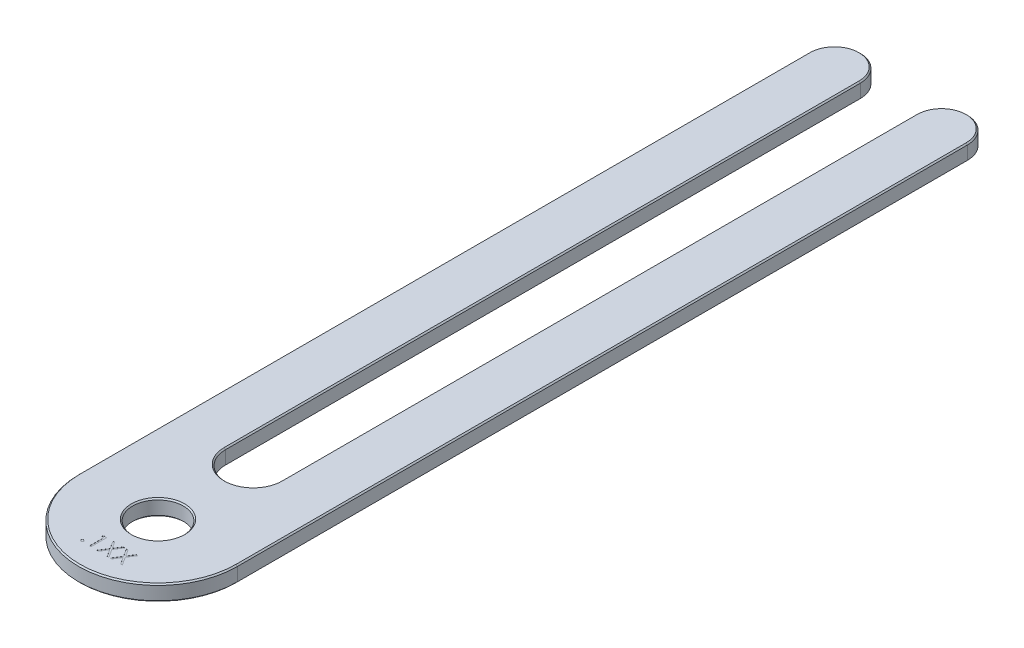
from build123d import *

# Parameters (mm, degrees)
SKETCH1_R          = 5.08
BASE_EXTRUDE_DEPTH = 1.5875
CHAMFER1_SIZE      = 0.254
EXTRUDE1_DEPTH     = 0.0254


with BuildPart() as part:
    # Sketch1 → Base-Extrude (new body, symmetric)
    with BuildSketch(Plane(origin=(0, 0, 0), x_dir=(1, 0, 0), z_dir=(0, 1, 0))):
        with BuildLine():
            Line((5.5499, 0), (5.5499, 127))
            ThreePointArc((5.5499, 127), (10.71245, 132.16255), (15.875, 127))
            Line((15.875, 127), (15.875, -19.05))
            ThreePointArc((15.875, -19.05), (0, -34.925), (-15.875, -19.05))
            Line((-15.875, -19.05), (-15.875, 127))
            ThreePointArc((-15.875, 127), (-10.71245, 132.16255), (-5.5499, 127))
            Line((-5.5499, 127), (-5.5499, 0))
            ThreePointArc((-5.5499, 0), (0, -5.5499), (5.5499, 0))
        make_face()
        with Locations(Location((0, -19.05, 0), (0, 0, 270))):  # turned: the seam where the file's is
            Circle(SKETCH1_R, mode=Mode.SUBTRACT)
    extrude(amount=BASE_EXTRUDE_DEPTH, both=True)

    # Chamfer1
    chamfer1_edges = [part.edges().sort_by_distance(p)[0] for p in [
        (-10.71245, 1.5875, -132.16255),
        (-5.5499, -1.5875, -63.5),
        (0, -1.5875, 5.5499),
        (-15.875, 1.5875, -53.975),
        (0, 1.5875, 34.925),
        (15.875, 1.5875, -53.975),
        (0, -1.5875, 13.97),
        (0, 1.5875, 13.97),
        (10.71245, 1.5875, -132.16255),
        (5.5499, 1.5875, -63.5),
        (0, 1.5875, 5.5499),
        (-5.5499, 1.5875, -63.5),
        (5.5499, -1.5875, -63.5),
        (10.71245, -1.5875, -132.16255),
        (15.875, -1.5875, -53.975),
        (0, -1.5875, 34.925),
        (-15.875, -1.5875, -53.975),
        (-10.71245, -1.5875, -132.16255),
    ]]
    chamfer(chamfer1_edges, length=CHAMFER1_SIZE)

    # Sketch2 → Extrude1 (cut)
    with BuildSketch(Plane(origin=(0, 1.5875, 0), x_dir=(1, 0, 0), z_dir=(0, 1, 0))):
        with BuildLine():
            add(Edge.make_bspline(
                [(-3.866987179, -30.058088124), (-3.849306773, -30.059138746), (-3.814646402, -30.061198369), (-3.764536622, -30.075328638), (-3.719184323, -30.100418994), (-3.678787215, -30.1338588), (-3.645489197, -30.174404152), (-3.619504678, -30.219394726), (-3.605497498, -30.269924028), (-3.603452878, -30.304785233), (-3.602403846, -30.322671457)],
                knots=[0, 0, 0, 0, 1.020151414, 1.999887582, 2.974338812, 3.990962822, 5.007586832, 5.987933904, 6.967670073, 8, 8, 8, 8], degree=3))
            add(Edge.make_bspline(
                [(-3.602403846, -30.322671457), (-3.603488427, -30.340127906), (-3.605627204, -30.374551768), (-3.61947257, -30.424699952), (-3.64568723, -30.469718643), (-3.678557545, -30.510814154), (-3.71919431, -30.544324801), (-3.764643842, -30.569201693), (-3.814528769, -30.584343703), (-3.849287148, -30.586272558), (-3.866987179, -30.58725479)],
                knots=[0, 0, 0, 0, 1.009421747, 1.99056486, 2.972319754, 3.999869655, 5.017953583, 5.993804169, 6.978383603, 8, 8, 8, 8], degree=3))
            add(Edge.make_bspline(
                [(-3.866987179, -30.58725479), (-3.884699965, -30.586308099), (-3.919279963, -30.584459908), (-3.968978686, -30.568890791), (-4.014705008, -30.544558081), (-4.055333861, -30.51075167), (-4.088479474, -30.469930112), (-4.113539643, -30.424389911), (-4.128589278, -30.374695321), (-4.130568548, -30.340156181), (-4.131570513, -30.322671457)],
                knots=[0, 0, 0, 0, 1.022052826, 1.995314843, 2.982371812, 4.00089066, 5.028879526, 6.005146991, 6.990147033, 8, 8, 8, 8], degree=3))
            add(Edge.make_bspline(
                [(-4.131570513, -30.322671457), (-4.130607037, -30.304755948), (-4.128725969, -30.269778116), (-4.113508049, -30.21970464), (-4.088673913, -30.174194699), (-4.055104734, -30.133920658), (-4.014714837, -30.100186463), (-3.969088993, -30.075634829), (-3.919160268, -30.061083883), (-3.884679823, -30.059104029), (-3.866987179, -30.058088124)],
                knots=[0, 0, 0, 0, 1.032775665, 2.016367738, 2.991239715, 4.008302682, 5.025365648, 6.011011707, 6.979408107, 8, 8, 8, 8], degree=3))
        make_face()
        Polygon((-2.520537861, -27.371549662), (-1.93349359, -27.371549662), (-1.93349359, -30.546549662), (-2.218429487, -30.546549662), (-2.218429487, -27.697190688), (-2.706891026, -27.697190688), align=None)
        Polygon((-0.691987179, -27.371549662), (-0.363166066, -27.371549662), (0.468108974, -28.670297659), (1.299384014, -27.371549662), (1.628205128, -27.371549662), (0.63283754, -28.927248781), (1.668910256, -30.546549662), (1.340089143, -30.546549662), (0.468108974, -29.184199903), (-0.403871194, -30.546549662), (-0.732692308, -30.546549662), (0.304016426, -28.927248781), align=None)
        Polygon((1.994551282, -27.371549662), (2.323372396, -27.371549662), (3.154647436, -28.670297659), (3.985922476, -27.371549662), (4.31474359, -27.371549662), (3.319376002, -28.927248781), (4.355448718, -30.546549662), (4.026627604, -30.546549662), (3.154647436, -29.184199903), (2.282667268, -30.546549662), (1.953846154, -30.546549662), (2.990554888, -28.927248781), align=None)
    extrude(amount=-EXTRUDE1_DEPTH, mode=Mode.SUBTRACT)


solid = part.part
